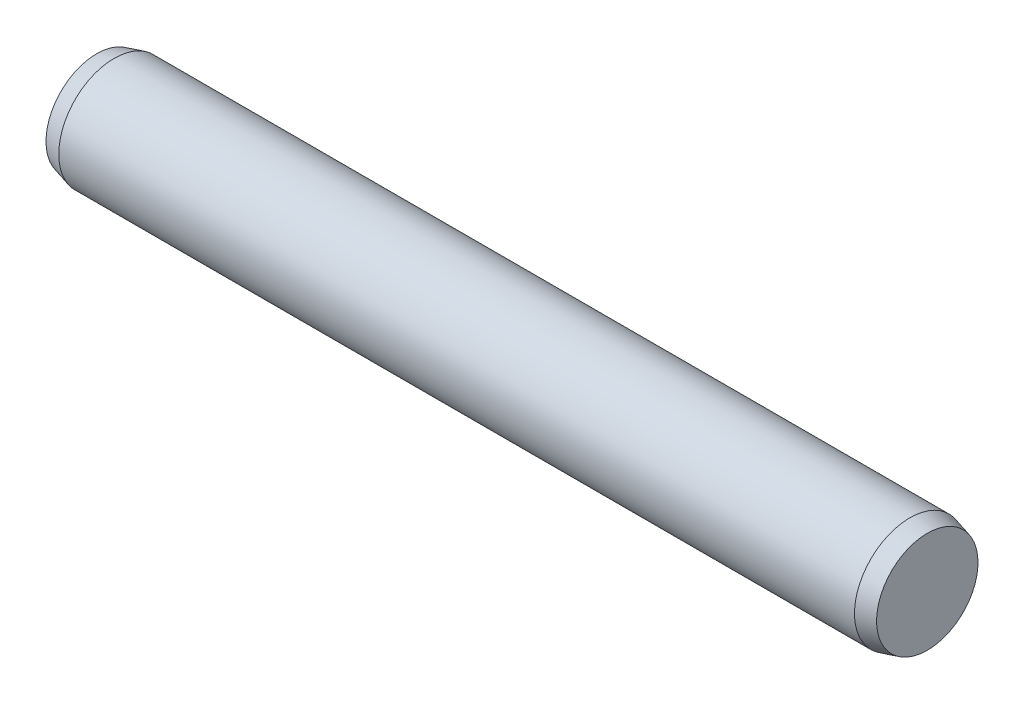
from build123d import *

# Parameters (mm, degrees)
SKETCH2_R           = 2
EXTRUDE1_DEPTH      = 14.37
EXTRUDE1_DEPTH_BACK = 14.37
SKETCH3_R           = 2
EXTRUDE2_DEPTH      = 0.63
EXTRUDE2_TAPER      = 15
SKETCH4_R           = 2
EXTRUDE3_DEPTH      = 0.63
EXTRUDE3_TAPER      = 15


with BuildPart() as part:
    # Sketch2 → Extrude1 (new body, two sides)
    with BuildSketch(Plane(origin=(0, 0, 0), x_dir=(0, 0, -1), z_dir=(1, 0, 0))) as extrude1_sk:
        Circle(SKETCH2_R)
    extrude(amount=EXTRUDE1_DEPTH)
    extrude(extrude1_sk.sketch, amount=-EXTRUDE1_DEPTH_BACK)

    # Sketch3 → Extrude2 (add)
    with BuildSketch(Plane(origin=(14.37, 0, 0), x_dir=(0, 0, -1), z_dir=(1, 0, 0))):
        Circle(SKETCH3_R)
    extrude(amount=EXTRUDE2_DEPTH, taper=EXTRUDE2_TAPER)

    # Sketch4 → Extrude3 (add)
    with BuildSketch(Plane.ZY.offset(14.37)):
        Circle(SKETCH4_R)
    extrude(amount=EXTRUDE3_DEPTH, taper=EXTRUDE3_TAPER)


solid = part.part
